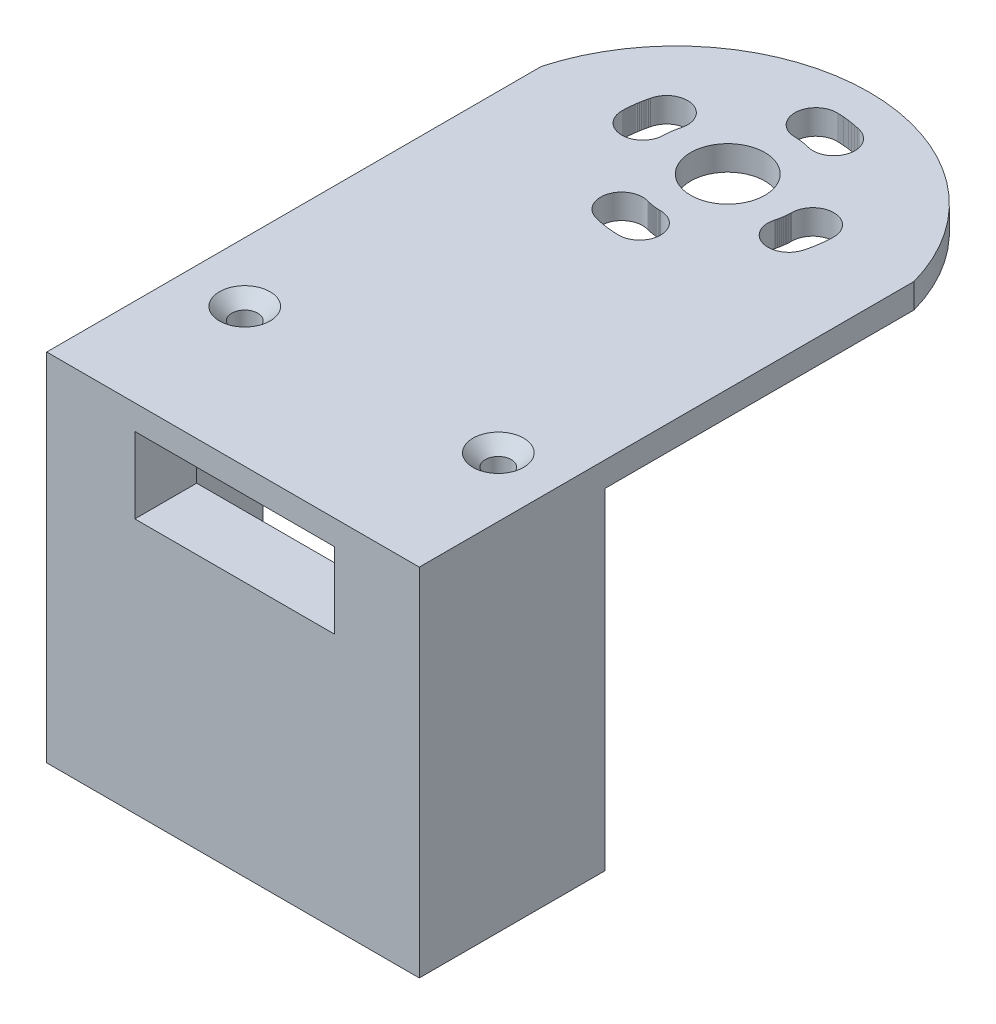
from build123d import *

# Parameters (mm, degrees)
BOSS_EXTRUDE1_DEPTH          = 32.5
SKETCH4_R                    = 1.05
BOSS_EXTRUDE2_DEPTH          = 2.5
SKETCH5_R                    = 1.05
BOSS_EXTRUDE3_DEPTH          = 3
CUT_EXTRUDE1_DEPTH           = 31.122
SKETCH13_W                   = 30.122
SKETCH13_H                   = 38
BOSS_EXTRUDE7_DEPTH          = 2.5
SKETCH14_W                   = 16.142040697
SKETCH14_H                   = 6.124158174
CUT_EXTRUDE2_DEPTH           = 1
CUT_EXTRUDE2_DEPTH_BACK      = 16
SKETCH15_W                   = 30.122
SKETCH15_H                   = 2
BOSS_EXTRUDE8_DEPTH          = 40
BOSS_EXTRUDE8_DEPTH_BACK     = 15
SKETCH16_R                   = 3
CUT_EXTRUDE3_DEPTH           = 1
CUT_EXTRUDE3_DEPTH_BACK      = 41
CUT_EXTRUDE4_START           = -41
SKETCH17_R                   = 1.7
CUT_EXTRUDE4_DEPTH           = 42
CIRPATTERN1_COUNT            = 15
CIRPATTERN1_ANGLE            = 14
CIRPATTERN2_COUNT            = 4
CIRPATTERN2_START            = -41
CIRPATTERN2_COPY_1_SKETCH_R  = 1.7
CIRPATTERN2_COPY_1_DEPTH     = 42
CIRPATTERN2_COPY_2_SKETCH_R  = 1.7
CIRPATTERN2_COPY_2_DEPTH     = 42
CIRPATTERN2_COPY_3_SKETCH_R  = 1.7
CIRPATTERN2_COPY_3_DEPTH     = 42
CIRPATTERN2_COPY_4_SKETCH_R  = 1.7
CIRPATTERN2_COPY_4_DEPTH     = 42
CIRPATTERN2_COPY_5_SKETCH_R  = 1.7
CIRPATTERN2_COPY_5_DEPTH     = 42
CIRPATTERN2_COPY_6_SKETCH_R  = 1.7
CIRPATTERN2_COPY_6_DEPTH     = 42
CIRPATTERN2_COPY_7_SKETCH_R  = 1.7
CIRPATTERN2_COPY_7_DEPTH     = 42
CIRPATTERN2_COPY_8_SKETCH_R  = 1.7
CIRPATTERN2_COPY_8_DEPTH     = 42
CIRPATTERN2_COPY_9_SKETCH_R  = 1.7
CIRPATTERN2_COPY_9_DEPTH     = 42
CIRPATTERN2_COPY_10_SKETCH_R = 1.7
CIRPATTERN2_COPY_10_DEPTH    = 42
CIRPATTERN2_COPY_11_SKETCH_R = 1.7
CIRPATTERN2_COPY_11_DEPTH    = 42
CIRPATTERN2_COPY_12_SKETCH_R = 1.7
CIRPATTERN2_COPY_12_DEPTH    = 42
CIRPATTERN2_COPY_13_SKETCH_R = 1.7
CIRPATTERN2_COPY_13_DEPTH    = 42
CIRPATTERN2_COPY_14_SKETCH_R = 1.7
CIRPATTERN2_COPY_14_DEPTH    = 42
CIRPATTERN2_COPY_15_SKETCH_R = 1.7
CIRPATTERN2_COPY_15_DEPTH    = 42
CIRPATTERN2_COPY_16_SKETCH_R = 1.7
CIRPATTERN2_COPY_16_DEPTH    = 42
CIRPATTERN2_COPY_17_SKETCH_R = 1.7
CIRPATTERN2_COPY_17_DEPTH    = 42
CIRPATTERN2_COPY_18_SKETCH_R = 1.7
CIRPATTERN2_COPY_18_DEPTH    = 42
CIRPATTERN2_COPY_19_SKETCH_R = 1.7
CIRPATTERN2_COPY_19_DEPTH    = 42
CIRPATTERN2_COPY_20_SKETCH_R = 1.7
CIRPATTERN2_COPY_20_DEPTH    = 42
CIRPATTERN2_COPY_21_SKETCH_R = 1.7
CIRPATTERN2_COPY_21_DEPTH    = 42
CIRPATTERN2_COPY_22_SKETCH_R = 1.7
CIRPATTERN2_COPY_22_DEPTH    = 42
CIRPATTERN2_COPY_23_SKETCH_R = 1.7
CIRPATTERN2_COPY_23_DEPTH    = 42
CIRPATTERN2_COPY_24_SKETCH_R = 1.7
CIRPATTERN2_COPY_24_DEPTH    = 42
CIRPATTERN2_COPY_25_SKETCH_R = 1.7
CIRPATTERN2_COPY_25_DEPTH    = 42
CIRPATTERN2_COPY_26_SKETCH_R = 1.7
CIRPATTERN2_COPY_26_DEPTH    = 42
CIRPATTERN2_COPY_27_SKETCH_R = 1.7
CIRPATTERN2_COPY_27_DEPTH    = 42
CIRPATTERN2_COPY_28_SKETCH_R = 1.7
CIRPATTERN2_COPY_28_DEPTH    = 42
CIRPATTERN2_COPY_29_SKETCH_R = 1.7
CIRPATTERN2_COPY_29_DEPTH    = 42
CIRPATTERN2_COPY_30_SKETCH_R = 1.7
CIRPATTERN2_COPY_30_DEPTH    = 42
CIRPATTERN2_COPY_31_SKETCH_R = 1.7
CIRPATTERN2_COPY_31_DEPTH    = 42
CIRPATTERN2_COPY_32_SKETCH_R = 1.7
CIRPATTERN2_COPY_32_DEPTH    = 42
CIRPATTERN2_COPY_33_SKETCH_R = 1.7
CIRPATTERN2_COPY_33_DEPTH    = 42
CIRPATTERN2_COPY_34_SKETCH_R = 1.7
CIRPATTERN2_COPY_34_DEPTH    = 42
CIRPATTERN2_COPY_35_SKETCH_R = 1.7
CIRPATTERN2_COPY_35_DEPTH    = 42
CIRPATTERN2_COPY_36_SKETCH_R = 1.7
CIRPATTERN2_COPY_36_DEPTH    = 42
CIRPATTERN2_COPY_37_SKETCH_R = 1.7
CIRPATTERN2_COPY_37_DEPTH    = 42
CIRPATTERN2_COPY_38_SKETCH_R = 1.7
CIRPATTERN2_COPY_38_DEPTH    = 42
CIRPATTERN2_COPY_39_SKETCH_R = 1.7
CIRPATTERN2_COPY_39_DEPTH    = 42
CIRPATTERN2_COPY_40_SKETCH_R = 1.7
CIRPATTERN2_COPY_40_DEPTH    = 42
CIRPATTERN2_COPY_41_SKETCH_R = 1.7
CIRPATTERN2_COPY_41_DEPTH    = 42
CIRPATTERN2_COPY_42_SKETCH_R = 1.7
CIRPATTERN2_COPY_42_DEPTH    = 42
SKETCH19_W                   = 30.122
SKETCH19_H                   = 15.908265354
CUT_EXTRUDE5_DEPTH           = 41
CUT_EXTRUDE5_DEPTH_BACK      = 16
CUT_EXTRUDE8_DEPTH           = 1
CUT_EXTRUDE8_DEPTH_BACK      = 29.770077576
SKETCH24_R                   = 1.05
CUT_EXTRUDE9_DEPTH           = 6
CHAMFER1_SIZE                = 1


with BuildPart() as part:
    # Sketch2 → Boss-Extrude1 (new body)
    with BuildSketch(Plane(origin=(0, 0, 0), x_dir=(1, 0, 0), z_dir=(0, 1, 0))):
        Polygon((15.061, 0), (15.061, 32), (12.561, 32), (12.561, 2.5), (-12.561, 2.5), (-12.561, 32), (-15.061, 32), (-15.061, 0), align=None)
    extrude(amount=BOSS_EXTRUDE1_DEPTH)

    # Sketch4 → Boss-Extrude2 (add)
    with BuildSketch(Plane.XZ):
        Polygon((-7.561, -6), (-7.561, 0), (-15.061, 0), (-15.061, -32), (-12.561, -32), (-12.561, -10), align=None)
        with Locations((-10.2499, -4.95)):
            Circle(SKETCH4_R, mode=Mode.SUBTRACT)
        Polygon((12.561, -10), (7.561, -6), (7.561, 0), (15.061, 0), (15.061, -32), (12.561, -32), align=None)
        with Locations((10.2499, -4.95)):
            Circle(SKETCH4_R, mode=Mode.SUBTRACT)
    extrude(amount=BOSS_EXTRUDE2_DEPTH)

    # Sketch5 → Boss-Extrude3 (add)
    with BuildSketch(Plane(origin=(0, 32.5, 0), x_dir=(1, 0, 0), z_dir=(0, 1, 0))):
        Polygon((-15.061, 32), (-10.2499, 32), (-6.25, 26), (6.25, 26), (10.2499, 32), (15.061, 32), (15.061, 0), (-15.061, 0), align=None)
        with Locations((-10.2499, 8.7)):
            Circle(SKETCH5_R, mode=Mode.SUBTRACT)
        with Locations((10.2499, 8.7)):
            Circle(SKETCH5_R, mode=Mode.SUBTRACT)
    extrude(amount=BOSS_EXTRUDE3_DEPTH)

    # Sketch6 → Cut-Extrude1 (cut, through all)
    with BuildSketch(Plane.ZY.offset(15.061)):
        Polygon((-32, -2.5), (-32, 29.699762375), (-32, 35.5), (-12.5, 35.5), (-12.5, -2.5), align=None)
    extrude(amount=-CUT_EXTRUDE1_DEPTH, mode=Mode.SUBTRACT)

    # Sketch13 → Boss-Extrude7 (add)
    with BuildSketch(Plane.XY):
        with Locations((0, 16.5)):
            Rectangle(SKETCH13_W, SKETCH13_H)
    extrude(amount=BOSS_EXTRUDE7_DEPTH)

    # Sketch14 → Cut-Extrude2 (cut, two sides)
    with BuildSketch(Plane.XY.offset(2.5)) as cut_extrude2_sk:
        with Locations((0.134966896, 32.437920913)):
            Rectangle(SKETCH14_W, SKETCH14_H)
    extrude(amount=CUT_EXTRUDE2_DEPTH, mode=Mode.SUBTRACT)
    extrude(cut_extrude2_sk.sketch, amount=-CUT_EXTRUDE2_DEPTH_BACK, mode=Mode.SUBTRACT)

    # Sketch15 → Boss-Extrude8 (add, two sides)
    with BuildSketch(Plane(origin=(0, 0, -12.5), x_dir=(-1, 0, 0), z_dir=(0, 0, -1))) as boss_extrude8_sk:
        with Locations((0, 36.5)):
            Rectangle(SKETCH15_W, SKETCH15_H)
    extrude(amount=BOSS_EXTRUDE8_DEPTH)
    extrude(boss_extrude8_sk.sketch, amount=-BOSS_EXTRUDE8_DEPTH_BACK)

    # Sketch16 → Cut-Extrude3 (cut, two sides)
    with BuildSketch(Plane(origin=(0, 37.5, 0), x_dir=(1, 0, 0), z_dir=(0, 1, 0))) as cut_extrude3_sk:
        with Locations((0, 37.5)):
            Circle(SKETCH16_R)
    extrude(amount=CUT_EXTRUDE3_DEPTH, mode=Mode.SUBTRACT)
    extrude(cut_extrude3_sk.sketch, amount=-CUT_EXTRUDE3_DEPTH_BACK, mode=Mode.SUBTRACT)

    # Sketch17 → Cut-Extrude4 (cut)
    with BuildSketch(Plane(origin=(0, 37.5, 0), x_dir=(1, 0, 0), z_dir=(0, 1, 0)).offset(CUT_EXTRUDE4_START)):
        with Locations((1.816219873, 44.260277019)):
            Circle(SKETCH17_R)
    cut_extrude4 = extrude(amount=CUT_EXTRUDE4_DEPTH, mode=Mode.SUBTRACT)

    # CirPattern1: Cut-Extrude4 ×15 about axis
    cirpattern1_axis = Axis((0, 0, -37.5), (0, 1, 0))
    for i in range(1, CIRPATTERN1_COUNT):
        add(cut_extrude4.rotate(cirpattern1_axis, i * CIRPATTERN1_ANGLE / (CIRPATTERN1_COUNT - 1)), mode=Mode.SUBTRACT)

    # CirPattern2: Cut-Extrude4 ×4 about axis
    cirpattern2_axis = Axis((0, 35.5, -37.5), (0, 1, 0))
    for i in range(1, CIRPATTERN2_COUNT):
        add(cut_extrude4.rotate(cirpattern2_axis, i * 360 / CIRPATTERN2_COUNT), mode=Mode.SUBTRACT)

    # CirPattern2 copy 1 sketch → CirPattern2 copy 1 (cut)
    with BuildSketch(Plane(origin=(37.494288568, 37.5, -38.154465241), x_dir=(-0.017452406, 0, -0.999847695), z_dir=(0, 1, 0)).offset(CIRPATTERN2_START)):
        with Locations((1.816219873, 44.260277019)):
            Circle(CIRPATTERN2_COPY_1_SKETCH_R)
    extrude(amount=CIRPATTERN2_COPY_1_DEPTH, mode=Mode.SUBTRACT)

    # CirPattern2 copy 2 sketch → CirPattern2 copy 2 (cut)
    with BuildSketch(Plane(origin=(-0.654465241, 37.5, -74.994288568), x_dir=(-0.999847695, 0, 0.017452406), z_dir=(0, 1, 0)).offset(CIRPATTERN2_START)):
        with Locations((1.816219873, 44.260277019)):
            Circle(CIRPATTERN2_COPY_2_SKETCH_R)
    extrude(amount=CIRPATTERN2_COPY_2_DEPTH, mode=Mode.SUBTRACT)

    # CirPattern2 copy 3 sketch → CirPattern2 copy 3 (cut)
    with BuildSketch(Plane(origin=(-37.494288568, 37.5, -36.845534759), x_dir=(0.017452406, 0, 0.999847695), z_dir=(0, 1, 0)).offset(CIRPATTERN2_START)):
        with Locations((1.816219873, 44.260277019)):
            Circle(CIRPATTERN2_COPY_3_SKETCH_R)
    extrude(amount=CIRPATTERN2_COPY_3_DEPTH, mode=Mode.SUBTRACT)

    # CirPattern2 copy 4 sketch → CirPattern2 copy 4 (cut)
    with BuildSketch(Plane(origin=(37.477156013, 37.5, -38.808731126), x_dir=(-0.034899497, 0, -0.999390827), z_dir=(0, 1, 0)).offset(CIRPATTERN2_START)):
        with Locations((1.816219873, 44.260277019)):
            Circle(CIRPATTERN2_COPY_4_SKETCH_R)
    extrude(amount=CIRPATTERN2_COPY_4_DEPTH, mode=Mode.SUBTRACT)

    # CirPattern2 copy 5 sketch → CirPattern2 copy 5 (cut)
    with BuildSketch(Plane(origin=(-1.308731126, 37.5, -74.977156013), x_dir=(-0.999390827, 0, 0.034899497), z_dir=(0, 1, 0)).offset(CIRPATTERN2_START)):
        with Locations((1.816219873, 44.260277019)):
            Circle(CIRPATTERN2_COPY_5_SKETCH_R)
    extrude(amount=CIRPATTERN2_COPY_5_DEPTH, mode=Mode.SUBTRACT)

    # CirPattern2 copy 6 sketch → CirPattern2 copy 6 (cut)
    with BuildSketch(Plane(origin=(-37.477156013, 37.5, -36.191268874), x_dir=(0.034899497, 0, 0.999390827), z_dir=(0, 1, 0)).offset(CIRPATTERN2_START)):
        with Locations((1.816219873, 44.260277019)):
            Circle(CIRPATTERN2_COPY_6_SKETCH_R)
    extrude(amount=CIRPATTERN2_COPY_6_DEPTH, mode=Mode.SUBTRACT)

    # CirPattern2 copy 7 sketch → CirPattern2 copy 7 (cut)
    with BuildSketch(Plane(origin=(37.448607553, 37.5, -39.462598359), x_dir=(-0.052335956, 0, -0.998629535), z_dir=(0, 1, 0)).offset(CIRPATTERN2_START)):
        with Locations((1.816219873, 44.260277019)):
            Circle(CIRPATTERN2_COPY_7_SKETCH_R)
    extrude(amount=CIRPATTERN2_COPY_7_DEPTH, mode=Mode.SUBTRACT)

    # CirPattern2 copy 8 sketch → CirPattern2 copy 8 (cut)
    with BuildSketch(Plane(origin=(-1.962598359, 37.5, -74.948607553), x_dir=(-0.998629535, 0, 0.052335956), z_dir=(0, 1, 0)).offset(CIRPATTERN2_START)):
        with Locations((1.816219873, 44.260277019)):
            Circle(CIRPATTERN2_COPY_8_SKETCH_R)
    extrude(amount=CIRPATTERN2_COPY_8_DEPTH, mode=Mode.SUBTRACT)

    # CirPattern2 copy 9 sketch → CirPattern2 copy 9 (cut)
    with BuildSketch(Plane(origin=(-37.448607553, 37.5, -35.537401641), x_dir=(0.052335956, 0, 0.998629535), z_dir=(0, 1, 0)).offset(CIRPATTERN2_START)):
        with Locations((1.816219873, 44.260277019)):
            Circle(CIRPATTERN2_COPY_9_SKETCH_R)
    extrude(amount=CIRPATTERN2_COPY_9_DEPTH, mode=Mode.SUBTRACT)

    # CirPattern2 copy 10 sketch → CirPattern2 copy 10 (cut)
    with BuildSketch(Plane(origin=(37.408651885, 37.5, -40.115867765), x_dir=(-0.069756474, 0, -0.99756405), z_dir=(0, 1, 0)).offset(CIRPATTERN2_START)):
        with Locations((1.816219873, 44.260277019)):
            Circle(CIRPATTERN2_COPY_10_SKETCH_R)
    extrude(amount=CIRPATTERN2_COPY_10_DEPTH, mode=Mode.SUBTRACT)

    # CirPattern2 copy 11 sketch → CirPattern2 copy 11 (cut)
    with BuildSketch(Plane(origin=(-2.615867765, 37.5, -74.908651885), x_dir=(-0.99756405, 0, 0.069756474), z_dir=(0, 1, 0)).offset(CIRPATTERN2_START)):
        with Locations((1.816219873, 44.260277019)):
            Circle(CIRPATTERN2_COPY_11_SKETCH_R)
    extrude(amount=CIRPATTERN2_COPY_11_DEPTH, mode=Mode.SUBTRACT)

    # CirPattern2 copy 12 sketch → CirPattern2 copy 12 (cut)
    with BuildSketch(Plane(origin=(-37.408651885, 37.5, -34.884132235), x_dir=(0.069756474, 0, 0.99756405), z_dir=(0, 1, 0)).offset(CIRPATTERN2_START)):
        with Locations((1.816219873, 44.260277019)):
            Circle(CIRPATTERN2_COPY_12_SKETCH_R)
    extrude(amount=CIRPATTERN2_COPY_12_DEPTH, mode=Mode.SUBTRACT)

    # CirPattern2 copy 13 sketch → CirPattern2 copy 13 (cut)
    with BuildSketch(Plane(origin=(37.357301178, 37.5, -40.768340353), x_dir=(-0.087155743, 0, -0.996194698), z_dir=(0, 1, 0)).offset(CIRPATTERN2_START)):
        with Locations((1.816219873, 44.260277019)):
            Circle(CIRPATTERN2_COPY_13_SKETCH_R)
    extrude(amount=CIRPATTERN2_COPY_13_DEPTH, mode=Mode.SUBTRACT)

    # CirPattern2 copy 14 sketch → CirPattern2 copy 14 (cut)
    with BuildSketch(Plane(origin=(-3.268340353, 37.5, -74.857301178), x_dir=(-0.996194698, 0, 0.087155743), z_dir=(0, 1, 0)).offset(CIRPATTERN2_START)):
        with Locations((1.816219873, 44.260277019)):
            Circle(CIRPATTERN2_COPY_14_SKETCH_R)
    extrude(amount=CIRPATTERN2_COPY_14_DEPTH, mode=Mode.SUBTRACT)

    # CirPattern2 copy 15 sketch → CirPattern2 copy 15 (cut)
    with BuildSketch(Plane(origin=(-37.357301178, 37.5, -34.231659647), x_dir=(0.087155743, 0, 0.996194698), z_dir=(0, 1, 0)).offset(CIRPATTERN2_START)):
        with Locations((1.816219873, 44.260277019)):
            Circle(CIRPATTERN2_COPY_15_SKETCH_R)
    extrude(amount=CIRPATTERN2_COPY_15_DEPTH, mode=Mode.SUBTRACT)

    # CirPattern2 copy 16 sketch → CirPattern2 copy 16 (cut)
    with BuildSketch(Plane(origin=(37.294571076, 37.5, -41.419817373), x_dir=(-0.104528463, 0, -0.994521895), z_dir=(0, 1, 0)).offset(CIRPATTERN2_START)):
        with Locations((1.816219873, 44.260277019)):
            Circle(CIRPATTERN2_COPY_16_SKETCH_R)
    extrude(amount=CIRPATTERN2_COPY_16_DEPTH, mode=Mode.SUBTRACT)

    # CirPattern2 copy 17 sketch → CirPattern2 copy 17 (cut)
    with BuildSketch(Plane(origin=(-3.919817373, 37.5, -74.794571076), x_dir=(-0.994521895, 0, 0.104528463), z_dir=(0, 1, 0)).offset(CIRPATTERN2_START)):
        with Locations((1.816219873, 44.260277019)):
            Circle(CIRPATTERN2_COPY_17_SKETCH_R)
    extrude(amount=CIRPATTERN2_COPY_17_DEPTH, mode=Mode.SUBTRACT)

    # CirPattern2 copy 18 sketch → CirPattern2 copy 18 (cut)
    with BuildSketch(Plane(origin=(-37.294571076, 37.5, -33.580182627), x_dir=(0.104528463, 0, 0.994521895), z_dir=(0, 1, 0)).offset(CIRPATTERN2_START)):
        with Locations((1.816219873, 44.260277019)):
            Circle(CIRPATTERN2_COPY_18_SKETCH_R)
    extrude(amount=CIRPATTERN2_COPY_18_DEPTH, mode=Mode.SUBTRACT)

    # CirPattern2 copy 19 sketch → CirPattern2 copy 19 (cut)
    with BuildSketch(Plane(origin=(37.220480687, 37.5, -42.070100378), x_dir=(-0.121869343, 0, -0.992546152), z_dir=(0, 1, 0)).offset(CIRPATTERN2_START)):
        with Locations((1.816219873, 44.260277019)):
            Circle(CIRPATTERN2_COPY_19_SKETCH_R)
    extrude(amount=CIRPATTERN2_COPY_19_DEPTH, mode=Mode.SUBTRACT)

    # CirPattern2 copy 20 sketch → CirPattern2 copy 20 (cut)
    with BuildSketch(Plane(origin=(-4.570100378, 37.5, -74.720480687), x_dir=(-0.992546152, 0, 0.121869343), z_dir=(0, 1, 0)).offset(CIRPATTERN2_START)):
        with Locations((1.816219873, 44.260277019)):
            Circle(CIRPATTERN2_COPY_20_SKETCH_R)
    extrude(amount=CIRPATTERN2_COPY_20_DEPTH, mode=Mode.SUBTRACT)

    # CirPattern2 copy 21 sketch → CirPattern2 copy 21 (cut)
    with BuildSketch(Plane(origin=(-37.220480687, 37.5, -32.929899622), x_dir=(0.121869343, 0, 0.992546152), z_dir=(0, 1, 0)).offset(CIRPATTERN2_START)):
        with Locations((1.816219873, 44.260277019)):
            Circle(CIRPATTERN2_COPY_21_SKETCH_R)
    extrude(amount=CIRPATTERN2_COPY_21_DEPTH, mode=Mode.SUBTRACT)

    # CirPattern2 copy 22 sketch → CirPattern2 copy 22 (cut)
    with BuildSketch(Plane(origin=(37.135052578, 37.5, -42.718991286), x_dir=(-0.139173101, 0, -0.990268069), z_dir=(0, 1, 0)).offset(CIRPATTERN2_START)):
        with Locations((1.816219873, 44.260277019)):
            Circle(CIRPATTERN2_COPY_22_SKETCH_R)
    extrude(amount=CIRPATTERN2_COPY_22_DEPTH, mode=Mode.SUBTRACT)

    # CirPattern2 copy 23 sketch → CirPattern2 copy 23 (cut)
    with BuildSketch(Plane(origin=(-5.218991286, 37.5, -74.635052578), x_dir=(-0.990268069, 0, 0.139173101), z_dir=(0, 1, 0)).offset(CIRPATTERN2_START)):
        with Locations((1.816219873, 44.260277019)):
            Circle(CIRPATTERN2_COPY_23_SKETCH_R)
    extrude(amount=CIRPATTERN2_COPY_23_DEPTH, mode=Mode.SUBTRACT)

    # CirPattern2 copy 24 sketch → CirPattern2 copy 24 (cut)
    with BuildSketch(Plane(origin=(-37.135052578, 37.5, -32.281008714), x_dir=(0.139173101, 0, 0.990268069), z_dir=(0, 1, 0)).offset(CIRPATTERN2_START)):
        with Locations((1.816219873, 44.260277019)):
            Circle(CIRPATTERN2_COPY_24_SKETCH_R)
    extrude(amount=CIRPATTERN2_COPY_24_DEPTH, mode=Mode.SUBTRACT)

    # CirPattern2 copy 25 sketch → CirPattern2 copy 25 (cut)
    with BuildSketch(Plane(origin=(37.038312772, 37.5, -43.366292439), x_dir=(-0.156434465, 0, -0.987688341), z_dir=(0, 1, 0)).offset(CIRPATTERN2_START)):
        with Locations((1.816219873, 44.260277019)):
            Circle(CIRPATTERN2_COPY_25_SKETCH_R)
    extrude(amount=CIRPATTERN2_COPY_25_DEPTH, mode=Mode.SUBTRACT)

    # CirPattern2 copy 26 sketch → CirPattern2 copy 26 (cut)
    with BuildSketch(Plane(origin=(-5.866292439, 37.5, -74.538312772), x_dir=(-0.987688341, 0, 0.156434465), z_dir=(0, 1, 0)).offset(CIRPATTERN2_START)):
        with Locations((1.816219873, 44.260277019)):
            Circle(CIRPATTERN2_COPY_26_SKETCH_R)
    extrude(amount=CIRPATTERN2_COPY_26_DEPTH, mode=Mode.SUBTRACT)

    # CirPattern2 copy 27 sketch → CirPattern2 copy 27 (cut)
    with BuildSketch(Plane(origin=(-37.038312772, 37.5, -31.633707561), x_dir=(0.156434465, 0, 0.987688341), z_dir=(0, 1, 0)).offset(CIRPATTERN2_START)):
        with Locations((1.816219873, 44.260277019)):
            Circle(CIRPATTERN2_COPY_27_SKETCH_R)
    extrude(amount=CIRPATTERN2_COPY_27_DEPTH, mode=Mode.SUBTRACT)

    # CirPattern2 copy 28 sketch → CirPattern2 copy 28 (cut)
    with BuildSketch(Plane(origin=(36.930290738, 37.5, -44.011806663), x_dir=(-0.173648178, 0, -0.984807753), z_dir=(0, 1, 0)).offset(CIRPATTERN2_START)):
        with Locations((1.816219873, 44.260277019)):
            Circle(CIRPATTERN2_COPY_28_SKETCH_R)
    extrude(amount=CIRPATTERN2_COPY_28_DEPTH, mode=Mode.SUBTRACT)

    # CirPattern2 copy 29 sketch → CirPattern2 copy 29 (cut)
    with BuildSketch(Plane(origin=(-6.511806663, 37.5, -74.430290738), x_dir=(-0.984807753, 0, 0.173648178), z_dir=(0, 1, 0)).offset(CIRPATTERN2_START)):
        with Locations((1.816219873, 44.260277019)):
            Circle(CIRPATTERN2_COPY_29_SKETCH_R)
    extrude(amount=CIRPATTERN2_COPY_29_DEPTH, mode=Mode.SUBTRACT)

    # CirPattern2 copy 30 sketch → CirPattern2 copy 30 (cut)
    with BuildSketch(Plane(origin=(-36.930290738, 37.5, -30.988193337), x_dir=(0.173648178, 0, 0.984807753), z_dir=(0, 1, 0)).offset(CIRPATTERN2_START)):
        with Locations((1.816219873, 44.260277019)):
            Circle(CIRPATTERN2_COPY_30_SKETCH_R)
    extrude(amount=CIRPATTERN2_COPY_30_DEPTH, mode=Mode.SUBTRACT)

    # CirPattern2 copy 31 sketch → CirPattern2 copy 31 (cut)
    with BuildSketch(Plane(origin=(36.811019379, 37.5, -44.655337327), x_dir=(-0.190808995, 0, -0.981627183), z_dir=(0, 1, 0)).offset(CIRPATTERN2_START)):
        with Locations((1.816219873, 44.260277019)):
            Circle(CIRPATTERN2_COPY_31_SKETCH_R)
    extrude(amount=CIRPATTERN2_COPY_31_DEPTH, mode=Mode.SUBTRACT)

    # CirPattern2 copy 32 sketch → CirPattern2 copy 32 (cut)
    with BuildSketch(Plane(origin=(-7.155337327, 37.5, -74.311019379), x_dir=(-0.981627183, 0, 0.190808995), z_dir=(0, 1, 0)).offset(CIRPATTERN2_START)):
        with Locations((1.816219873, 44.260277019)):
            Circle(CIRPATTERN2_COPY_32_SKETCH_R)
    extrude(amount=CIRPATTERN2_COPY_32_DEPTH, mode=Mode.SUBTRACT)

    # CirPattern2 copy 33 sketch → CirPattern2 copy 33 (cut)
    with BuildSketch(Plane(origin=(-36.811019379, 37.5, -30.344662673), x_dir=(0.190808995, 0, 0.981627183), z_dir=(0, 1, 0)).offset(CIRPATTERN2_START)):
        with Locations((1.816219873, 44.260277019)):
            Circle(CIRPATTERN2_COPY_33_SKETCH_R)
    extrude(amount=CIRPATTERN2_COPY_33_DEPTH, mode=Mode.SUBTRACT)

    # CirPattern2 copy 34 sketch → CirPattern2 copy 34 (cut)
    with BuildSketch(Plane(origin=(36.680535028, 37.5, -45.296688406), x_dir=(-0.207911691, 0, -0.978147601), z_dir=(0, 1, 0)).offset(CIRPATTERN2_START)):
        with Locations((1.816219873, 44.260277019)):
            Circle(CIRPATTERN2_COPY_34_SKETCH_R)
    extrude(amount=CIRPATTERN2_COPY_34_DEPTH, mode=Mode.SUBTRACT)

    # CirPattern2 copy 35 sketch → CirPattern2 copy 35 (cut)
    with BuildSketch(Plane(origin=(-7.796688406, 37.5, -74.180535028), x_dir=(-0.978147601, 0, 0.207911691), z_dir=(0, 1, 0)).offset(CIRPATTERN2_START)):
        with Locations((1.816219873, 44.260277019)):
            Circle(CIRPATTERN2_COPY_35_SKETCH_R)
    extrude(amount=CIRPATTERN2_COPY_35_DEPTH, mode=Mode.SUBTRACT)

    # CirPattern2 copy 36 sketch → CirPattern2 copy 36 (cut)
    with BuildSketch(Plane(origin=(-36.680535028, 37.5, -29.703311594), x_dir=(0.207911691, 0, 0.978147601), z_dir=(0, 1, 0)).offset(CIRPATTERN2_START)):
        with Locations((1.816219873, 44.260277019)):
            Circle(CIRPATTERN2_COPY_36_SKETCH_R)
    extrude(amount=CIRPATTERN2_COPY_36_DEPTH, mode=Mode.SUBTRACT)

    # CirPattern2 copy 37 sketch → CirPattern2 copy 37 (cut)
    with BuildSketch(Plane(origin=(36.538877429, 37.5, -45.935664538), x_dir=(-0.224951054, 0, -0.974370065), z_dir=(0, 1, 0)).offset(CIRPATTERN2_START)):
        with Locations((1.816219873, 44.260277019)):
            Circle(CIRPATTERN2_COPY_37_SKETCH_R)
    extrude(amount=CIRPATTERN2_COPY_37_DEPTH, mode=Mode.SUBTRACT)

    # CirPattern2 copy 38 sketch → CirPattern2 copy 38 (cut)
    with BuildSketch(Plane(origin=(-8.435664538, 37.5, -74.038877429), x_dir=(-0.974370065, 0, 0.224951054), z_dir=(0, 1, 0)).offset(CIRPATTERN2_START)):
        with Locations((1.816219873, 44.260277019)):
            Circle(CIRPATTERN2_COPY_38_SKETCH_R)
    extrude(amount=CIRPATTERN2_COPY_38_DEPTH, mode=Mode.SUBTRACT)

    # CirPattern2 copy 39 sketch → CirPattern2 copy 39 (cut)
    with BuildSketch(Plane(origin=(-36.538877429, 37.5, -29.064335462), x_dir=(0.224951054, 0, 0.974370065), z_dir=(0, 1, 0)).offset(CIRPATTERN2_START)):
        with Locations((1.816219873, 44.260277019)):
            Circle(CIRPATTERN2_COPY_39_SKETCH_R)
    extrude(amount=CIRPATTERN2_COPY_39_DEPTH, mode=Mode.SUBTRACT)

    # CirPattern2 copy 40 sketch → CirPattern2 copy 40 (cut)
    with BuildSketch(Plane(origin=(36.386089735, 37.5, -46.572071085), x_dir=(-0.241921896, 0, -0.970295726), z_dir=(0, 1, 0)).offset(CIRPATTERN2_START)):
        with Locations((1.816219873, 44.260277019)):
            Circle(CIRPATTERN2_COPY_40_SKETCH_R)
    extrude(amount=CIRPATTERN2_COPY_40_DEPTH, mode=Mode.SUBTRACT)

    # CirPattern2 copy 41 sketch → CirPattern2 copy 41 (cut)
    with BuildSketch(Plane(origin=(-9.072071085, 37.5, -73.886089735), x_dir=(-0.970295726, 0, 0.241921896), z_dir=(0, 1, 0)).offset(CIRPATTERN2_START)):
        with Locations((1.816219873, 44.260277019)):
            Circle(CIRPATTERN2_COPY_41_SKETCH_R)
    extrude(amount=CIRPATTERN2_COPY_41_DEPTH, mode=Mode.SUBTRACT)

    # CirPattern2 copy 42 sketch → CirPattern2 copy 42 (cut)
    with BuildSketch(Plane(origin=(-36.386089735, 37.5, -28.427928915), x_dir=(0.241921896, 0, 0.970295726), z_dir=(0, 1, 0)).offset(CIRPATTERN2_START)):
        with Locations((1.816219873, 44.260277019)):
            Circle(CIRPATTERN2_COPY_42_SKETCH_R)
    extrude(amount=CIRPATTERN2_COPY_42_DEPTH, mode=Mode.SUBTRACT)

    # Sketch19 → Cut-Extrude5 (cut, two sides)
    with BuildSketch(Plane(origin=(0, 0, -12.5), x_dir=(-1, 0, 0), z_dir=(0, 0, -1))) as cut_extrude5_sk:
        with Locations((0, 0.775789747)):
            Rectangle(SKETCH19_W, SKETCH19_H)
    extrude(amount=CUT_EXTRUDE5_DEPTH, mode=Mode.SUBTRACT)
    extrude(cut_extrude5_sk.sketch, amount=-CUT_EXTRUDE5_DEPTH_BACK, mode=Mode.SUBTRACT)

    # Sketch23 → Cut-Extrude8 (cut, two sides)
    with BuildSketch(Plane(origin=(0, 37.5, 0), x_dir=(1, 0, 0), z_dir=(0, 1, 0))) as cut_extrude8_sk:
        with BuildLine():
            Line((-15.061, 37.5), (-15.061, 55.76270139))
            Line((-15.061, 55.76270139), (15.061, 55.135272524))
            Line((15.061, 55.135272524), (15.061, 37.5))
            ThreePointArc((15.061, 37.5), (0, 48.941783309), (-15.061, 37.5))
        make_face()
    extrude(amount=CUT_EXTRUDE8_DEPTH, mode=Mode.SUBTRACT)
    extrude(cut_extrude8_sk.sketch, amount=-CUT_EXTRUDE8_DEPTH_BACK, mode=Mode.SUBTRACT)

    # Sketch24 → Cut-Extrude9 (cut, through all)
    with BuildSketch(Plane.XZ.offset(-32.5)):
        with Locations((-10.2499, -8.7)):
            Circle(SKETCH24_R)
        with Locations((10.2499, -8.7)):
            Circle(SKETCH24_R)
    extrude(amount=-CUT_EXTRUDE9_DEPTH, mode=Mode.SUBTRACT)

    # Chamfer1
    chamfer1_edges = [part.edges().sort_by_distance(p)[0] for p in [
        (-11.2999, 37.5, -8.7),
        (9.1999, 37.5, -8.7),
    ]]
    chamfer(chamfer1_edges, length=CHAMFER1_SIZE)


solid = part.part
